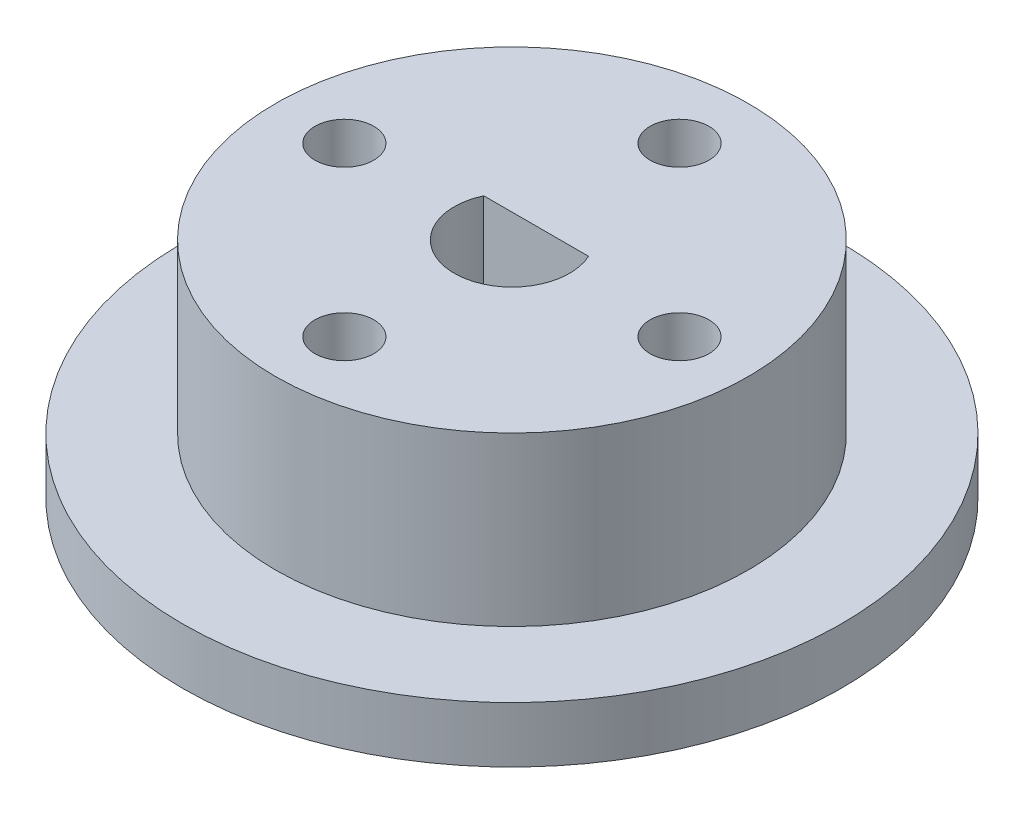
from build123d import *

# Parameters (mm, degrees)
SKETCH1_R               = 12.7
BOSS_EXTRUDE1_DEPTH     = 9
SKETCH2_R               = 17.7
BOSS_EXTRUDE2_DEPTH     = 3
SKETCH3_R               = 3.1
SKETCH3_R_2             = 1.58
CUT_EXTRUDE1_DEPTH      = 10
CUT_EXTRUDE1_DEPTH_BACK = 4
SKETCH4_R               = 3.1
BOSS_EXTRUDE3_DEPTH     = 5.5
SKETCH5_W               = 6.2
SKETCH5_H               = 1.8
BOSS_EXTRUDE4_DEPTH     = 6.5


with BuildPart() as part:
    # Sketch1 → Boss-Extrude1 (new body)
    with BuildSketch(Plane(origin=(0, 0, 0), x_dir=(1, 0, 0), z_dir=(0, 1, 0))):
        Circle(SKETCH1_R)
    extrude(amount=BOSS_EXTRUDE1_DEPTH)

    # Sketch2 → Boss-Extrude2 (add)
    with BuildSketch(Plane(origin=(0, 0, 0), x_dir=(-1, 0, 0), z_dir=(0, 1, 0))):
        Circle(SKETCH2_R)
    extrude(amount=-BOSS_EXTRUDE2_DEPTH)

    # Sketch3 → Cut-Extrude1 (cut, two sides)
    with BuildSketch(Plane(origin=(0, 0, 0), x_dir=(1, 0, 0), z_dir=(0, 1, 0))) as cut_extrude1_sk:
        Circle(SKETCH3_R)
        with Locations((-9, 0)):
            Circle(SKETCH3_R_2)
        with Locations((9, 0)):
            Circle(SKETCH3_R_2)
        with Locations((0, 9)):
            Circle(SKETCH3_R_2)
        with Locations((0, -9)):
            Circle(SKETCH3_R_2)
    extrude(amount=CUT_EXTRUDE1_DEPTH, mode=Mode.SUBTRACT)
    extrude(cut_extrude1_sk.sketch, amount=-CUT_EXTRUDE1_DEPTH_BACK, mode=Mode.SUBTRACT)

    # Sketch4 → Boss-Extrude3 (add)
    with BuildSketch(Plane.XZ.offset(3)):
        Circle(SKETCH4_R)
    extrude(amount=-BOSS_EXTRUDE3_DEPTH)

    # Sketch5 → Boss-Extrude4 (add)
    with BuildSketch(Plane(origin=(0, 9, 0), x_dir=(1, 0, 0), z_dir=(0, 1, 0))):
        with Locations((0, 2.2)):
            Rectangle(SKETCH5_W, SKETCH5_H)
    extrude(amount=-BOSS_EXTRUDE4_DEPTH)


solid = part.part
